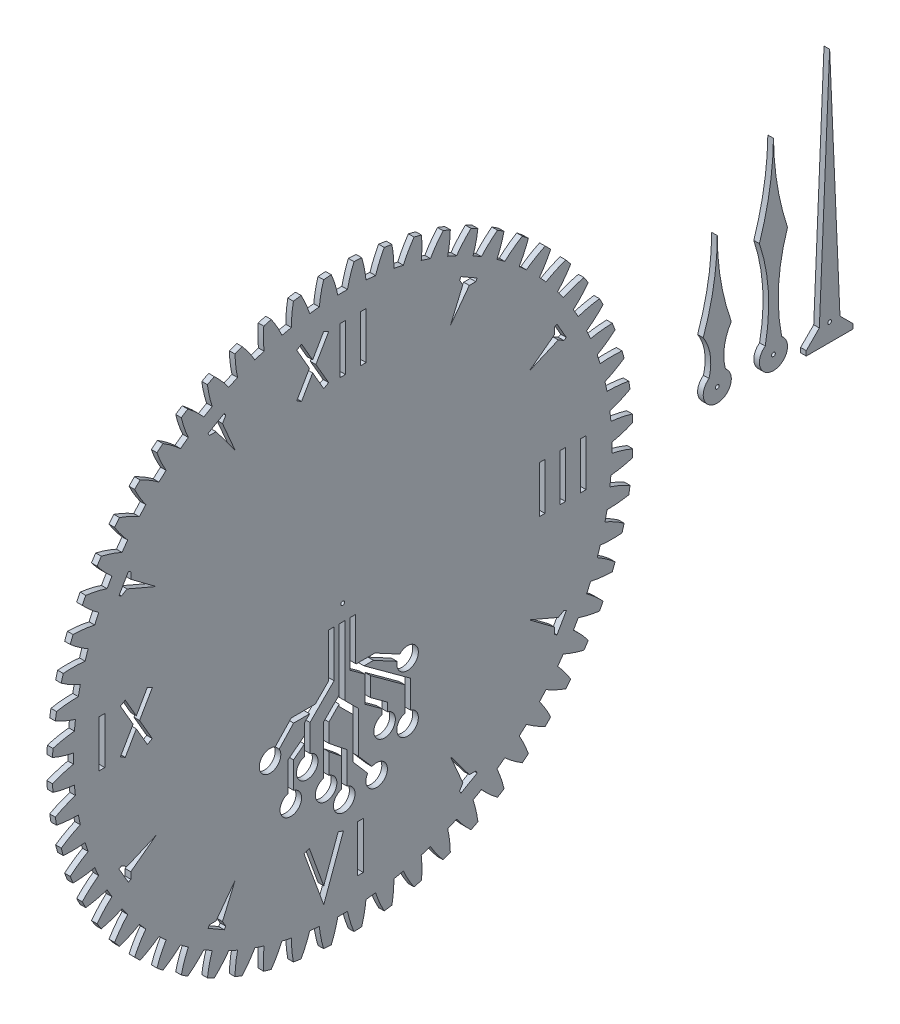
from build123d import *

# Parameters (mm, degrees)
BASPROSKE_W           = 3
BASPROSKE_H           = 155
TOOTHCUT_DEPTH        = 220.223630113
TEETHCUTS_COUNT       = 60
TEETHCUTS_ANGLE       = 354
BORSKE_R              = 1
BORE_DEPTH            = 50.0000508
CUT_EXTRUDE1_DEPTH    = 3
SKETCH3_W             = 3
SKETCH3_H             = 25
CUT_EXTRUDE2_DEPTH    = 10
CUT_EXTRUDE3_DEPTH    = 3
SKETCH5_R             = 1
BOSS_EXTRUDE1_DEPTH   = 3
BOSS_EXTRUDE1_2_DEPTH = 3
BOSS_EXTRUDE1_3_DEPTH = 3


with BuildPart() as part:
    # BasProSke → Base-Revolve (revolve)
    with BuildSketch(Plane(origin=(0, 0, 0), x_dir=(1, 0, 0), z_dir=(0, 1, 0)), mode=Mode.PRIVATE) as base_revolve_sk:
        with Locations((1.5, 77.5)):
            Rectangle(BASPROSKE_W, BASPROSKE_H)
    revolve(base_revolve_sk.sketch.rotate(Axis((-10, 0, 0), (1, 0, 0)), 180), axis=Axis((-10, 0, 0), (1, 0, 0)))

    # TooCutSke → ToothCut (cut, through all)
    with BuildSketch(Plane(origin=(0, 0, 0), x_dir=(0, 0, -1), z_dir=(1, 0, 0))):
        with BuildLine():
            ThreePointArc((2.58775774, 143.725705811), (0, 143.749), (-2.58775774, 143.725705811))
            ThreePointArc((-2.58775774, 143.725705811), (-4.04863683, 149.401178671), (-6.056235201, 154.907058136))
            ThreePointArc((-6.056235201, 154.907058136), (0, 155.0254), (6.056235201, 154.907058136))
            ThreePointArc((6.056235201, 154.907058136), (4.04863683, 149.401178671), (2.58775774, 143.725705811))
        make_face()
    toothcut = extrude(amount=TOOTHCUT_DEPTH, mode=Mode.SUBTRACT)

    # TeethCuts: ToothCut ×60 about axis
    teethcuts_axis = Axis((-10, 0, 0), (1, 0, 0))
    for i in range(1, TEETHCUTS_COUNT):
        add(toothcut.rotate(teethcuts_axis, i * TEETHCUTS_ANGLE / (TEETHCUTS_COUNT - 1)), mode=Mode.SUBTRACT)

    # BorSke → Bore (cut, symmetric)
    with BuildSketch(Plane(origin=(0, 0, 0), x_dir=(0, 0, -1), z_dir=(1, 0, 0))):
        with Locations(Location((0, 0, 0), (0, 0, 180))):
            Circle(BORSKE_R)
    extrude(amount=BORE_DEPTH, both=True, mode=Mode.SUBTRACT)

    # Sketch2 → Cut-Extrude1 (cut)
    with BuildSketch(Plane(origin=(3, 0, 0), x_dir=(0, 0, -1), z_dir=(1, 0, 0))):
        with BuildLine():
            Line((36.162689923, -52.742607496), (11.378482405, -34.666356069))
            Line((11.378482405, -34.666356069), (16.469278359, -34.666356069))
            Line((16.469278359, -34.666356069), (29.061812198, -41.418120426))
            ThreePointArc((29.061812198, -41.418120426), (39.730233884, -45.436221747), (30.479416703, -38.774184446))
            Line((30.479416703, -38.774184446), (17.222797452, -31.666356069))
            Line((17.222797452, -31.666356069), (7.265205775, -31.666356069))
            Line((7.265205775, -31.666356069), (6.905375794, -31.403915674))
            Line((6.905375794, -31.403915674), (6.905375794, -8.639236111))
            Line((6.905375794, -8.639236111), (3.905375794, -8.639236111))
            Line((3.905375794, -8.639236111), (3.905375794, -32.929031915))
            Line((3.905375794, -32.929031915), (11.801709085, -38.688187451))
            Line((11.801709085, -38.688187451), (11.801709085, -52.568013091))
            Line((11.801709085, -52.568013091), (20.890910883, -59.197181962))
            Line((20.890910883, -59.197181962), (20.890910883, -62.17094135))
            ThreePointArc((20.890910883, -62.17094135), (22.390910883, -73.471842177), (23.890910883, -62.17094135))
            Line((23.890910883, -62.17094135), (23.890910883, -57.672065721))
            Line((23.890910883, -57.672065721), (14.801709085, -51.04289685))
            Line((14.801709085, -51.04289685), (14.801709085, -40.876224097))
            Line((14.801709085, -40.876224097), (33.162689923, -54.267723738))
            Line((33.162689923, -54.267723738), (33.162689923, -67.504280883))
            ThreePointArc((33.162689923, -67.504280883), (34.662689923, -78.805181711), (36.162689923, -67.504280883))
            Line((36.162689923, -67.504280883), (36.162689923, -52.742607496))
        make_face()
        with BuildLine():
            Line((-26.181440865, -42.341006505), (-17.607579293, -42.341006505))
            Line((-17.607579293, -42.341006505), (-20.427861331, -45.161288542))
            Line((-20.427861331, -45.161288542), (-20.427861331, -51.071012028))
            Line((-20.427861331, -51.071012028), (-29.186367856, -57.870834513))
            Line((-29.186367856, -57.870834513), (-29.186367856, -73.458069764))
            ThreePointArc((-29.186367856, -73.458069764), (-27.686367856, -84.758970592), (-26.186367856, -73.458069764))
            Line((-26.186367856, -73.458069764), (-26.186367856, -59.339720397))
            Line((-26.186367856, -59.339720397), (-20.427861331, -54.869001327))
            Line((-20.427861331, -54.869001327), (-20.427861331, -60.791212306))
            ThreePointArc((-20.427861331, -60.791212306), (-18.927861331, -72.092113134), (-17.427861331, -60.791212306))
            Line((-17.427861331, -60.791212306), (-17.427861331, -46.40392923))
            Line((-17.427861331, -46.40392923), (-4.594624206, -33.570692105))
            Line((-4.594624206, -33.570692105), (-4.594624206, -8.639236111))
            Line((-4.594624206, -8.639236111), (-7.594624206, -8.639236111))
            Line((-7.594624206, -8.639236111), (-7.594624206, -32.328051418))
            Line((-7.594624206, -32.328051418), (-14.607579293, -39.341006505))
            Line((-14.607579293, -39.341006505), (-27.475802791, -39.341006505))
            Line((-27.475802791, -39.341006505), (-36.055384466, -48.4377839))
            ThreePointArc((-36.055384466, -48.4377839), (-42.717974116, -57.688203278), (-33.872930034, -50.496155259))
            Line((-33.872930034, -50.496155259), (-26.181440865, -42.341006505))
        make_face()
        with BuildLine():
            Line((-7.339014068, -75.942460271), (-7.339014068, -64.998567802))
            Line((-7.339014068, -64.998567802), (-0.641536421, -70.356586787))
            Line((-0.641536421, -70.356586787), (-0.641536421, -85.788405138))
            ThreePointArc((-0.641536421, -85.788405138), (0.858463579, -97.089305965), (2.358463579, -85.788405138))
            Line((2.358463579, -85.788405138), (2.358463579, -68.914718443))
            Line((2.358463579, -68.914718443), (-7.339014068, -61.156682944))
            Line((-7.339014068, -61.156682944), (-7.339014068, -51.234975252))
            Line((-7.339014068, -51.234975252), (-1.844624206, -45.74058539))
            Line((-1.844624206, -45.74058539), (-1.844624206, -46.839534476))
            Line((-1.844624206, -46.839534476), (5.442327279, -54.12648596))
            Line((5.442327279, -54.12648596), (5.442327279, -76.1150705))
            Line((5.442327279, -76.1150705), (13.374684523, -85.311472105))
            ThreePointArc((13.374684523, -85.311472105), (21.891696791, -92.889127517), (15.646373777, -83.352026282))
            Line((15.646373777, -83.352026282), (8.442327279, -74.999993874))
            Line((8.442327279, -74.999993874), (8.442327279, -52.883845273))
            Line((8.442327279, -52.883845273), (1.155375794, -45.596893788))
            Line((1.155375794, -45.596893788), (1.155375794, -8.639236111))
            Line((1.155375794, -8.639236111), (-1.844624206, -8.639236111))
            Line((-1.844624206, -8.639236111), (-1.844624206, -41.497944703))
            Line((-1.844624206, -41.497944703), (-10.339014068, -49.992334564))
            Line((-10.339014068, -49.992334564), (-10.339014068, -75.942460271))
            ThreePointArc((-10.339014068, -75.942460271), (-8.839014068, -87.243361099), (-7.339014068, -75.942460271))
        make_face()
    extrude(amount=-CUT_EXTRUDE1_DEPTH, mode=Mode.SUBTRACT)

    # Sketch3 → Cut-Extrude2 (cut)
    with BuildSketch(Plane(origin=(3, 0, 0), x_dir=(0, 0, -1), z_dir=(1, 0, 0))):
        Polygon((-16.015916471, 114.5), (-21.93375673, 104.25), (-24.531832941, 105.75), (-17.747967278, 117.5), (-24.531832941, 129.25), (-21.93375673, 130.75), (-16.015916471, 120.5), (-10.098076211, 130.75), (-7.5, 129.25), (-14.283865663, 117.5), (-7.5, 105.75), (-10.098076211, 104.25), align=None)
        with Locations((11, 117.5)):
            Rectangle(SKETCH3_W, SKETCH3_H)
        Polygon((-110.157036927, -3), (-116.074877186, -13.25), (-118.672953397, -11.75), (-111.889087734, 0), (-118.672953397, 11.75), (-116.074877186, 13.25), (-110.157036927, 3), (-104.239196668, 13.25), (-101.641120456, 11.75), (-108.424986119, 0), (-101.641120456, -11.75), (-104.239196668, -13.25), align=None)
        with Locations((-128.5, 0)):
            Rectangle(SKETCH3_W, SKETCH3_H)
        with Locations((106.5, 0)):
            Rectangle(SKETCH3_W, SKETCH3_H)
        with Locations((117.5, 0)):
            Rectangle(SKETCH3_W, SKETCH3_H)
        with Locations((128.5, 0)):
            Rectangle(SKETCH3_W, SKETCH3_H)
        Polygon((-2.409538931, -104.486969785), (0.409538931, -105.513030215), (-10.099255857, -134.3857066), (-20.608050644, -105.513030215), (-17.788972782, -104.486969785), (-10.099255857, -125.6142934), align=None)
        with Locations((9.5, -117.5)):
            Rectangle(SKETCH3_W, SKETCH3_H)
        with Locations((0, 117.5)):
            Rectangle(SKETCH3_W, SKETCH3_H)
    extrude(amount=-CUT_EXTRUDE2_DEPTH, mode=Mode.SUBTRACT)

    # Sketch4 → Cut-Extrude3 (cut)
    with BuildSketch(Plane(origin=(3, 0, 0), x_dir=(0, 0, -1), z_dir=(1, 0, 0))):
        Polygon((71.830127019, 114.413429511), (63.169872981, 119.413429511), (62.419872981, 118.114391405), (64.151923789, 115.114391405), (57.5, 99.592921435), (67.616025404, 113.114391405), (71.080127019, 113.114391405), align=None)
        Polygon((113.114391405, 71.080127019), (113.114391405, 67.616025404), (99.592921435, 57.5), (115.114391405, 64.151923789), (118.114391405, 62.419872981), (119.413429511, 63.169872981), (114.413429511, 71.830127019), align=None)
        Polygon((114.413429511, -71.830127019), (113.114391405, -71.080127019), (113.114391405, -67.616025404), (99.592921435, -57.5), (115.114391405, -64.151923789), (118.114391405, -62.419872981), (119.413429511, -63.169872981), align=None)
        Polygon((71.080127019, -113.114391405), (67.616025404, -113.114391405), (57.5, -99.592921435), (64.151923789, -115.114391405), (62.419872981, -118.114391405), (63.169872981, -119.413429511), (71.830127019, -114.413429511), align=None)
        Polygon((-71.830127019, -114.413429511), (-71.080127019, -113.114391405), (-67.616025404, -113.114391405), (-57.5, -99.592921435), (-64.151923789, -115.114391405), (-62.419872981, -118.114391405), (-63.169872981, -119.413429511), align=None)
        Polygon((-114.413429511, -71.830127019), (-119.413429511, -63.169872981), (-118.114391405, -62.419872981), (-115.114391405, -64.151923789), (-99.592921435, -57.5), (-113.114391405, -67.616025404), (-113.114391405, -71.080127019), align=None)
        Polygon((-114.413429511, 71.830127019), (-113.114391405, 71.080127019), (-113.114391405, 67.616025404), (-99.592921435, 57.5), (-115.114391405, 64.151923789), (-118.114391405, 62.419872981), (-119.413429511, 63.169872981), align=None)
        Polygon((-71.080127019, 113.114391405), (-67.616025404, 113.114391405), (-57.5, 99.592921435), (-64.151923789, 115.114391405), (-62.419872981, 118.114391405), (-63.169872981, 119.413429511), (-71.830127019, 114.413429511), align=None)
    extrude(amount=-CUT_EXTRUDE3_DEPTH, mode=Mode.SUBTRACT)


with BuildPart() as body_2:
    # Sketch5 → Boss-Extrude1 (new body)
    with BuildSketch(Plane(origin=(3, 0, 0), x_dir=(0, 0, -1), z_dir=(1, 0, 0))):
        with BuildLine():
            ThreePointArc((200, 70), (201.888720247, 47.920597834), (207.5, 26.482762036))
            ThreePointArc((207.5, 26.482762036), (203.745390624, 16.61279496), (204.400759717, 6.073163419))
            ThreePointArc((204.400759717, 6.073163419), (200, -7.5), (195.599240283, 6.073163419))
            ThreePointArc((195.599240283, 6.073163419), (196.254609376, 16.61279496), (192.5, 26.482762036))
            ThreePointArc((192.5, 26.482762036), (198.111279753, 47.920597834), (200, 70))
        make_face()
        with Locations((200, 0)):
            Circle(SKETCH5_R, mode=Mode.SUBTRACT)
    extrude(amount=-BOSS_EXTRUDE1_DEPTH)


with BuildPart() as body_3:
    # Sketch5 → Boss-Extrude1 2 (new body)
    with BuildSketch(Plane(origin=(3, 0, 0), x_dir=(0, 0, -1), z_dir=(1, 0, 0))):
        with BuildLine():
            ThreePointArc((230, 100), (232.029216571, 77.213202762), (237.5, 55))
            ThreePointArc((237.5, 55), (232.739927458, 30.739945837), (234.400759717, 6.073163419))
            ThreePointArc((234.400759717, 6.073163419), (230, -7.5), (225.599240283, 6.073163419))
            ThreePointArc((225.599240283, 6.073163419), (227.260072542, 30.739945837), (222.5, 55))
            ThreePointArc((222.5, 55), (227.970783429, 77.213202762), (230, 100))
        make_face()
        with Locations((230, 0)):
            Circle(SKETCH5_R, mode=Mode.SUBTRACT)
    extrude(amount=-BOSS_EXTRUDE1_2_DEPTH)


with BuildPart() as body_4:
    # Sketch5 → Boss-Extrude1 3 (new body)
    with BuildSketch(Plane(origin=(3, 0, 0), x_dir=(0, 0, -1), z_dir=(1, 0, 0))):
        Polygon((260, 126.121916163), (265.506601781, 0), (272.5, -6.993398219), (272.5, -9.493398219), (255.837969251, -9.493398219), (247.5, -9.493398219), (247.5, -6.993398219), (254.493398219, 0), align=None)
        with Locations((260, 0)):
            Circle(SKETCH5_R, mode=Mode.SUBTRACT)
    extrude(amount=-BOSS_EXTRUDE1_3_DEPTH)


solid = Compound([part.part, body_2.part, body_3.part, body_4.part])
